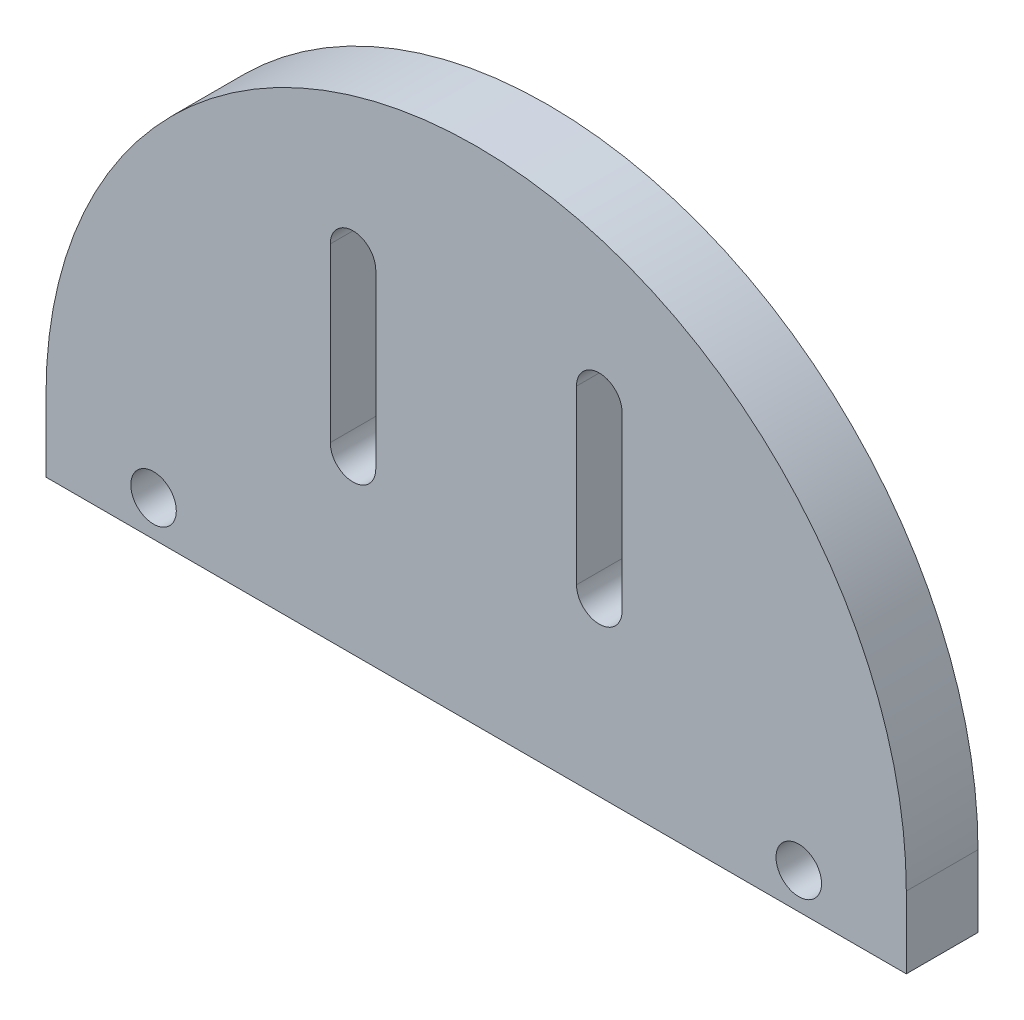
from build123d import *

# Parameters (mm, degrees)
CROQUIS1_R              = 1.5875
SALIENTE_EXTRUIR1_DEPTH = 5


with BuildPart() as part:
    # Croquis1 → Saliente-Extruir1 (new body)
    with BuildSketch(Plane.XY):
        with BuildLine():
            Line((-30, 0), (-30, -5))
            Line((-30, -5), (30, -5))
            Line((30, -5), (30, 0))
            ThreePointArc((30, 0), (0, 30), (-30, 0))
        make_face()
        with Locations((-22.5, -2.5)):
            Circle(CROQUIS1_R, mode=Mode.SUBTRACT)
        with Locations((22.5, -2.5)):
            Circle(CROQUIS1_R, mode=Mode.SUBTRACT)
        with BuildLine():
            Line((-10.175, 7), (-10.175, 19))
            ThreePointArc((-10.175, 19), (-8.5875, 20.5875), (-7, 19))
            Line((-7, 19), (-7, 7))
            ThreePointArc((-7, 7), (-8.5875, 5.4125), (-10.175, 7))
        make_face(mode=Mode.SUBTRACT)
        with BuildLine():
            Line((7, 7), (7, 19))
            ThreePointArc((7, 19), (8.5875, 20.5875), (10.175, 19))
            Line((10.175, 19), (10.175, 7))
            ThreePointArc((10.175, 7), (8.5875, 5.4125), (7, 7))
        make_face(mode=Mode.SUBTRACT)
    extrude(amount=SALIENTE_EXTRUIR1_DEPTH)


solid = part.part
